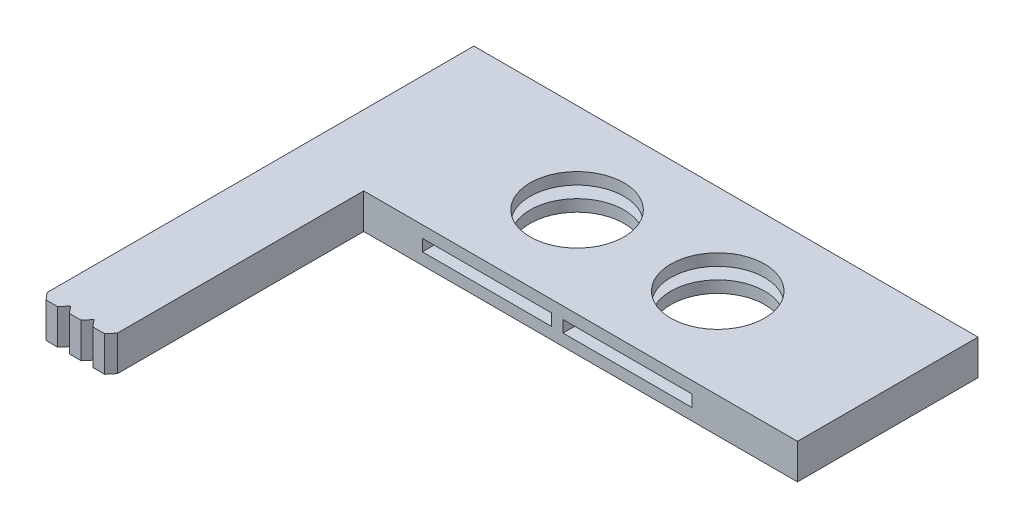
from build123d import *

# Parameters (mm, degrees)
SKETCH1_R           = 4
BOSS_EXTRUDE1_DEPTH = 3
SKETCH2_W           = 11
SKETCH2_H           = 1
CUT_EXTRUDE1_DEPTH  = 13.4


with BuildPart() as part:
    # Sketch1 → Boss-Extrude1 (new body)
    with BuildSketch(Plane(origin=(0, 0, 0), x_dir=(1, 0, 0), z_dir=(0, 1, 0))):
        Polygon((43, 7.7), (43, -7.7), (6, -7.7), (6, -28.7), (5.499093619, -29.3), (4.500906381, -29.3), (4, -28.7), (3.499093619, -29.3), (2.500906381, -29.3), (2, -28.7), (1.499093619, -29.3), (0.500906381, -29.3), (0, -28.7), (0, 7.7), align=None)
        with Locations((16.5, 0)):
            Circle(SKETCH1_R, mode=Mode.SUBTRACT)
        with Locations((28.5, 0)):
            Circle(SKETCH1_R, mode=Mode.SUBTRACT)
    extrude(amount=BOSS_EXTRUDE1_DEPTH)

    # Sketch2 → Cut-Extrude1 (cut)
    with BuildSketch(Plane.XY.offset(7.7)):
        with Locations((16.5, 1.5)):
            Rectangle(SKETCH2_W, SKETCH2_H)
        with Locations((28.5, 1.5)):
            Rectangle(SKETCH2_W, SKETCH2_H)
    extrude(amount=-CUT_EXTRUDE1_DEPTH, mode=Mode.SUBTRACT)


solid = part.part
